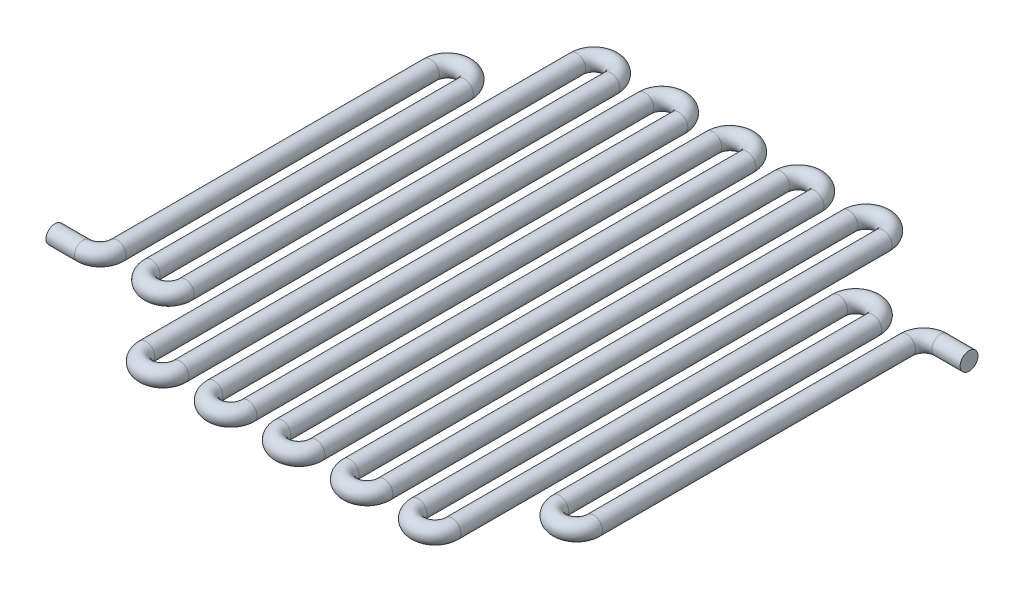
from build123d import *

# Parameters (mm, degrees)
SKETCH74_R              = 1.00000054
CUT_EXTRUDE4_DEPTH      = 49.965474539
CUT_EXTRUDE4_DEPTH_BACK = 49.965474539
SKETCH71_W              = 73.76617856
SKETCH71_H              = 63.5
SKETCH71_W_2            = 50.974683991


with BuildPart() as part:
    # Sweep4: sweep along a path in Sketch73
    with BuildLine(Plane(origin=(0, 0, 0), x_dir=(1, 0, 0), z_dir=(0, 1, 0))) as sweep4_path:
        Line((39.061357686, 19.158948776), (28.575, 19.158948776))
        ThreePointArc((28.575, 19.158948776), (27.227961582, 18.600987194), (26.67, 17.253948776))
        Line((26.67, 17.253948776), (26.67, -17.807552249))
        ThreePointArc((26.67, -17.807552249), (24.765, -19.712552249), (22.86, -17.807552249))
        Line((22.86, -17.807552249), (22.86, 17.253948776))
        ThreePointArc((22.86, 17.253948776), (20.955, 19.158948776), (19.05, 17.253948776))
        Line((19.05, 17.253948776), (19.05, -26.035))
        ThreePointArc((19.05, -26.035), (17.145, -27.94), (15.24, -26.035))
        Line((15.24, -26.035), (15.24, 26.035))
        ThreePointArc((15.24, 26.035), (13.335, 27.94), (11.43, 26.035))
        Line((11.43, 26.035), (11.43, -26.035))
        ThreePointArc((11.43, -26.035), (9.525, -27.94), (7.62, -26.035))
        Line((7.62, -26.035), (7.62, 26.035))
        ThreePointArc((7.62, 26.035), (5.715, 27.94), (3.81, 26.035))
        Line((3.81, 26.035), (3.81, -26.035))
        ThreePointArc((3.81, -26.035), (1.905, -27.94), (0, -26.035))
        Line((0, -26.035), (0, 26.035))
        ThreePointArc((0, 26.035), (-1.905, 27.94), (-3.81, 26.035))
        Line((-3.81, 26.035), (-3.81, -26.035))
        ThreePointArc((-3.81, -26.035), (-5.715, -27.94), (-7.62, -26.035))
        Line((-7.62, -26.035), (-7.62, 26.035))
        ThreePointArc((-7.62, 26.035), (-9.525, 27.94), (-11.43, 26.035))
        Line((-11.43, 26.035), (-11.43, -26.035))
        ThreePointArc((-11.43, -26.035), (-13.335, -27.94), (-15.24, -26.035))
        Line((-15.24, -26.035), (-15.24, 26.035))
        ThreePointArc((-15.24, 26.035), (-17.145, 27.94), (-19.05, 26.035))
        Line((-19.05, 26.035), (-19.05, -17.807552249))
        ThreePointArc((-19.05, -17.807552249), (-20.955, -19.712552249), (-22.86, -17.807552249))
        Line((-22.86, -17.807552249), (-22.86, 17.253948776))
        ThreePointArc((-22.86, 17.253948776), (-24.765, 19.158948776), (-26.67, 17.253948776))
        Line((-26.67, 17.253948776), (-26.67, -17.807552249))
        ThreePointArc((-26.67, -17.807552249), (-27.227961582, -19.154590667), (-28.575, -19.712552249))
        Line((-28.575, -19.712552249), (-39.485365118, -19.712552249))
    # Sketch74 → Sweep4 (sweep)
    with BuildSketch(Plane.XY):
        Circle(SKETCH74_R)
    sweep(path=sweep4_path.line)

    # Sketch71 → Cut-Extrude4 (cut, two sides: drawn at the far end of the back side and taken through both)
    with BuildSketch(Plane(origin=(0, 0, 0), x_dir=(1, 0, 0), z_dir=(0, 1, 0)).offset(-CUT_EXTRUDE4_DEPTH_BACK)):
        with Locations((68.63308928, 0)):
            Rectangle(SKETCH71_W, SKETCH71_H)
        with Locations((-57.237341996, 0)):
            Rectangle(SKETCH71_W_2, SKETCH71_H)
    extrude(amount=CUT_EXTRUDE4_DEPTH + CUT_EXTRUDE4_DEPTH_BACK, mode=Mode.SUBTRACT)


solid = part.part
